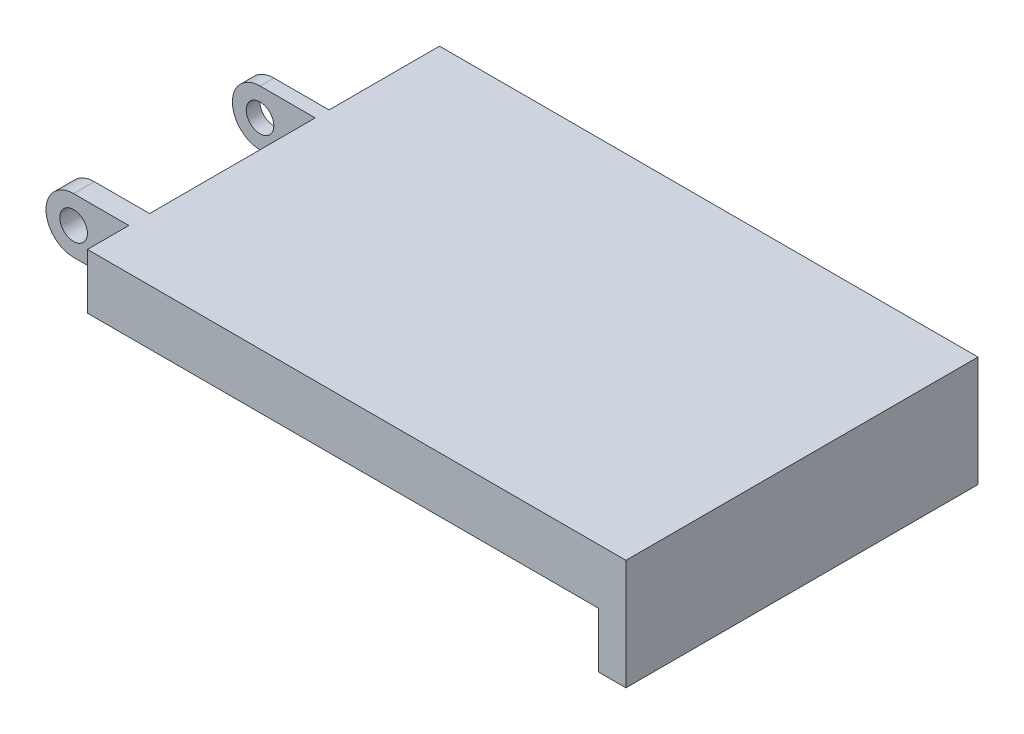
from build123d import *

# Parameters (mm, degrees)
SKETCH_1_R          = 1
EXTRUDE_1_DEPTH     = 25.5
SKETCH_2_W          = 8
SKETCH_2_H          = 4
CUT_EXTRUDE_2_DEPTH = 3
CUT_EXTRUDE_3_DEPTH = 8
CUT_EXTRUDE_START   = -9
CUT_EXTRUDE_4_DEPTH = 12
EXTRUDE_2_DEPTH     = 0.5


with BuildPart() as part:
    # 草图1 → 凸台-拉伸1 (new body)
    with BuildSketch(Plane.XY):
        with BuildLine():
            Line((0, 2), (43, 2))
            Line((43, 2), (43, -6))
            Line((43, -6), (41, -6))
            Line((41, -6), (41, -2))
            Line((41, -2), (0, -2))
            ThreePointArc((0, -2), (-2, 0), (0, 2))
        make_face()
        Circle(SKETCH_1_R, mode=Mode.SUBTRACT)
    extrude(amount=EXTRUDE_1_DEPTH)

    # 草图2 → 切除-拉伸2 (cut)
    with BuildSketch(Plane.XY.offset(25.5)):
        Rectangle(SKETCH_2_W, SKETCH_2_H)
    extrude(amount=-CUT_EXTRUDE_2_DEPTH, mode=Mode.SUBTRACT)

    # 草图3 → 切除-拉伸3 (cut)
    with BuildSketch(Plane(origin=(0, 0, 0), x_dir=(-1, 0, 0), z_dir=(0, 0, -1))):
        with BuildLine():
            Line((0, 2), (-4, 2))
            Line((-4, 2), (-4, -2))
            Line((-4, -2), (0, -2))
            ThreePointArc((0, -2), (2, 0), (0, 2))
        make_face()
    extrude(amount=-CUT_EXTRUDE_3_DEPTH, mode=Mode.SUBTRACT)

    # 草图3<2> → 切除-拉伸4 (cut)
    with BuildSketch(Plane(origin=(0, 0, 0), x_dir=(-1, 0, 0), z_dir=(0, 0, -1)).offset(CUT_EXTRUDE_START)):
        with BuildLine():
            ThreePointArc((0, -2), (2, 0), (0, 2))
            Line((0, 2), (-4, 2))
            Line((-4, 2), (-4, -2))
            Line((-4, -2), (0, -2))
        make_face()
    extrude(amount=-CUT_EXTRUDE_4_DEPTH, mode=Mode.SUBTRACT)

    # 草图4 → 凸台-拉伸2 (add)
    with BuildSketch(Plane.ZY.offset(-41)):
        Polygon((13.75, -5.068409561), (11.75, -5.068409561), (11.75, -6), (12.75, -6), (13.75, -6), align=None)
    extrude(amount=EXTRUDE_2_DEPTH)


solid = part.part
